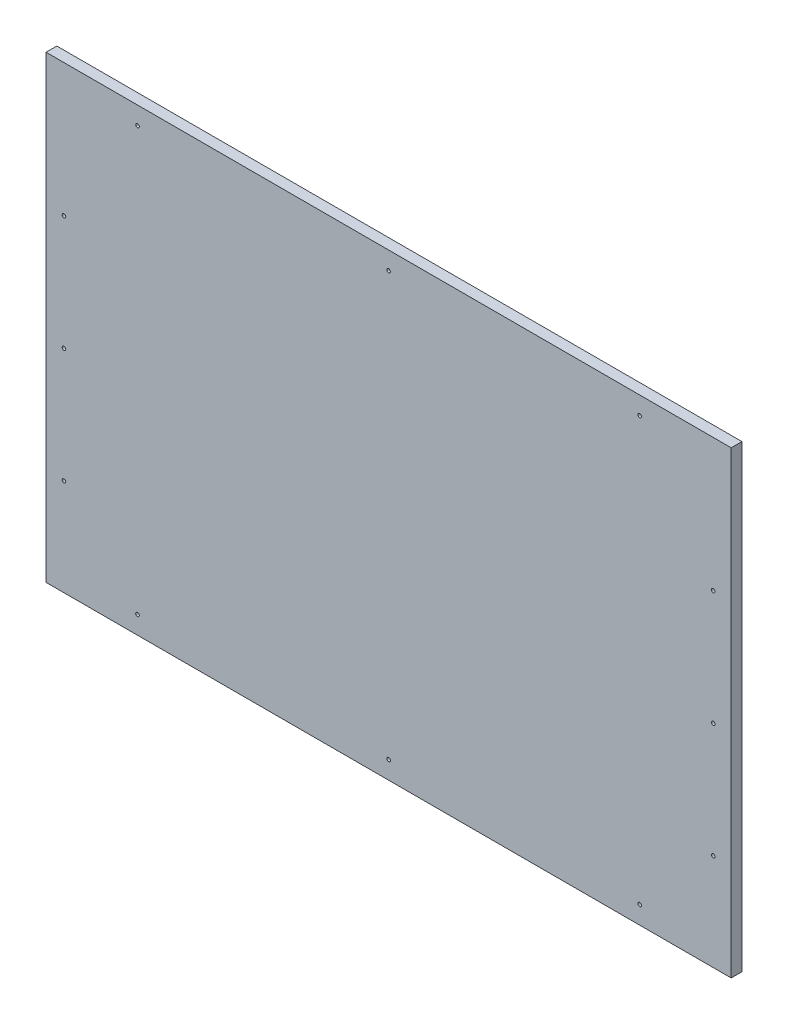
from build123d import *

# Parameters (mm, degrees)
SKETCH_1_W               = 955
SKETCH_1_H               = 640
EXTRUDE_1_DEPTH          = 15
CUT_EXTRUDE_1_DEPTH      = 576.005434757
CUT_EXTRUDE_1_DEPTH_BACK = 576.005434757
SKETCH_2_R               = 2.5
SKETCH_2_3_R             = 2.5
CUT_EXTRUDE_2_DEPTH      = 576.005434757


with BuildPart() as part:
    # ｽｹｯﾁ1 → ﾎﾞｽ - 押し出し1 (new body)
    with BuildSketch(Plane.XY):
        Rectangle(SKETCH_1_W, SKETCH_1_H)
    extrude(amount=EXTRUDE_1_DEPTH)

    # ｽｹｯﾁ2 → ｶｯﾄ - 押し出し1 (cut, two sides: drawn at the far end of the back side and taken through both)
    with BuildSketch(Plane.XY.offset(15).offset(-CUT_EXTRUDE_1_DEPTH_BACK)):
        with Locations((-452.5, 135)):
            Circle(SKETCH_2_R)
        with Locations((-452.5, -25)):
            Circle(SKETCH_2_R)
        with Locations((-452.5, -185)):
            Circle(SKETCH_2_R)
        with Locations((452.5, -25)):
            Circle(SKETCH_2_R)
        with Locations((452.5, -185)):
            Circle(SKETCH_2_R)
        with Locations((452.5, 135)):
            Circle(SKETCH_2_R)
    extrude(amount=CUT_EXTRUDE_1_DEPTH + CUT_EXTRUDE_1_DEPTH_BACK, mode=Mode.SUBTRACT)

    # ｽｹｯﾁ2<3> → ｶｯﾄ - 押し出し2 (cut, through all)
    with BuildSketch(Plane.XY.offset(15)):
        with Locations((0, 295)):
            Circle(SKETCH_2_3_R)
        with Locations((-350, 295)):
            Circle(SKETCH_2_3_R)
        with Locations((350, 295)):
            Circle(SKETCH_2_3_R)
    cut_extrude_2 = extrude(amount=-CUT_EXTRUDE_2_DEPTH, mode=Mode.SUBTRACT)

    # ﾐﾗｰ1: ｶｯﾄ - 押し出し2 across plane
    add(cut_extrude_2.mirror(Plane.ZX), mode=Mode.SUBTRACT)


solid = part.part
